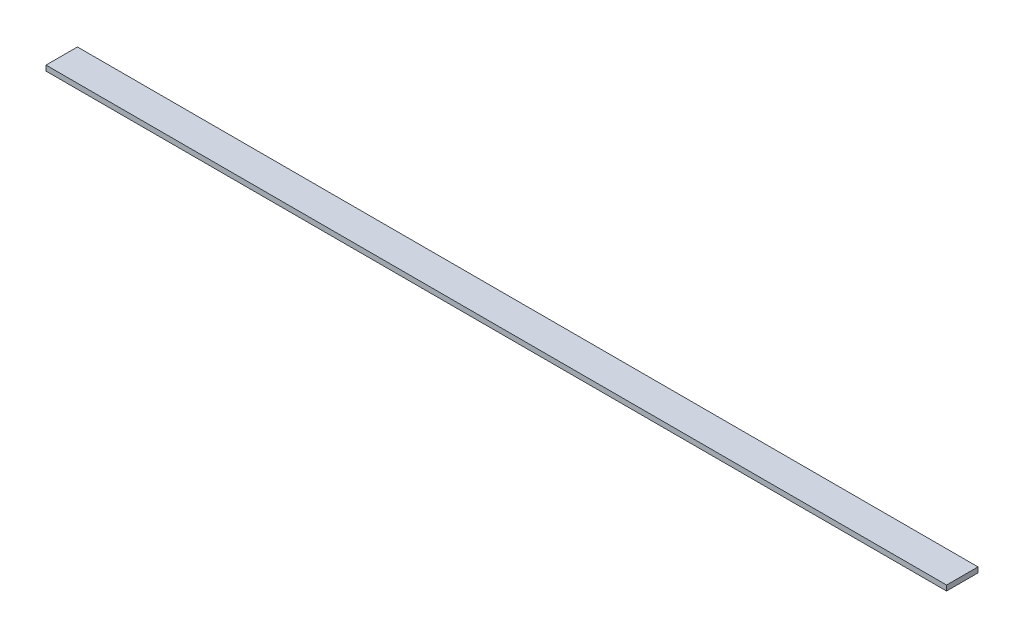
from build123d import *

# Parameters (mm, degrees)
SKETCH1_W           = 273.05
SKETCH1_H           = 9.525
BOSS_EXTRUDE1_DEPTH = 1.5875


with BuildPart() as part:
    # Sketch1 → Boss-Extrude1 (new body)
    with BuildSketch(Plane(origin=(0, 0, 0), x_dir=(1, 0, 0), z_dir=(0, 1, 0))):
        Rectangle(SKETCH1_W, SKETCH1_H)
    extrude(amount=BOSS_EXTRUDE1_DEPTH)


solid = part.part
